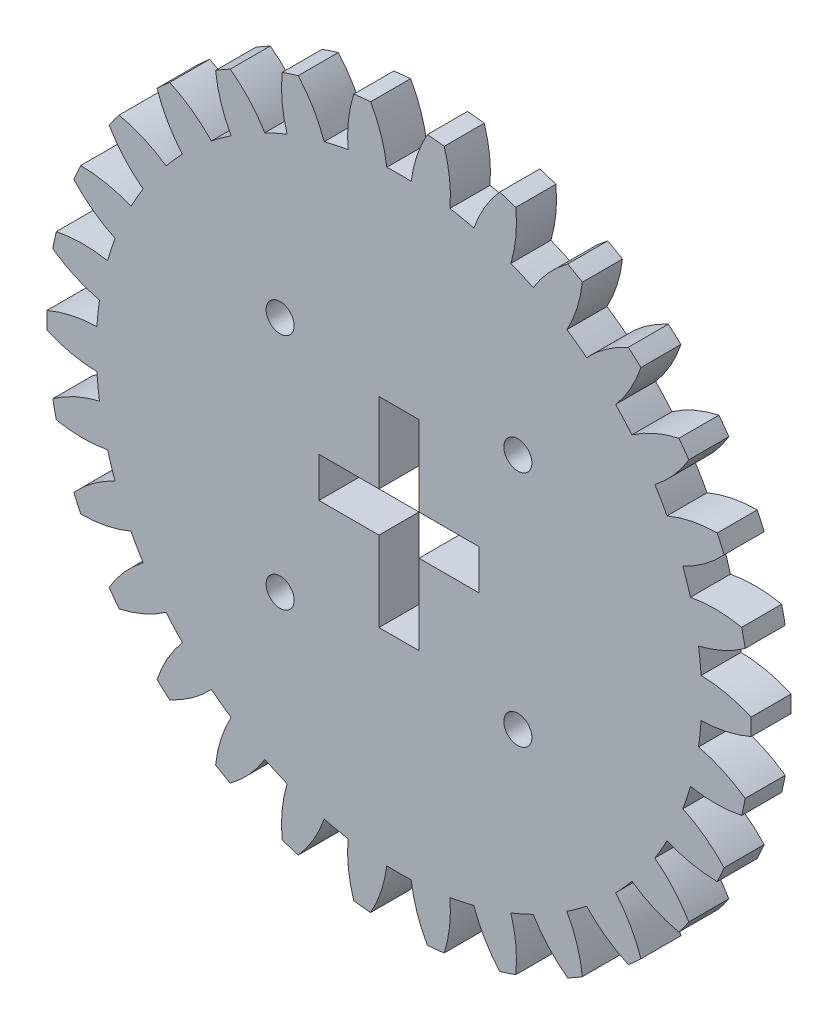
from build123d import *

# Parameters (mm, degrees)
EXTRUDE_1_DEPTH     = 5
SKETCH_2_R          = 1.75
CUT_EXTRUDE_1_DEPTH = 10
CUT_EXTRUDE_2_DEPTH = 10


with BuildPart() as part:
    # 草图1 → 凸台-拉伸1 (new body)
    with BuildSketch(Plane.XY):
        with BuildLine():
            ThreePointArc((-43.98730465, -1.056896208), (-40.927651292, -2.051995365), (-37.733051967, -2.434403732))
            ThreePointArc((-37.733051967, -2.434403732), (-37.604364647, -3.952377989), (-37.414635246, -5.463936465))
            ThreePointArc((-37.414635246, -5.463936465), (-40.459917741, -6.502182838), (-43.245817584, -8.111674394))
            ThreePointArc((-43.245817584, -8.111674394), (-43.038494432, -9.148114396), (-42.806335429, -10.179275375))
            ThreePointArc((-42.806335429, -10.179275375), (-39.606650089, -10.516491524), (-36.402353254, -10.226348803))
            ThreePointArc((-36.402353254, -10.226348803), (-35.960873466, -11.684396083), (-35.461019429, -13.123476419))
            ThreePointArc((-35.461019429, -13.123476419), (-38.223891636, -14.772184451), (-40.614280773, -16.925725901))
            ThreePointArc((-40.614280773, -16.925725901), (-40.196000136, -17.896412295), (-39.754523941, -18.856771362))
            ThreePointArc((-39.754523941, -18.856771362), (-36.554648223, -18.52136654), (-33.480697026, -17.571353361))
            ThreePointArc((-33.480697026, -17.571353361), (-32.745719555, -18.90575), (-31.957586902, -20.20945748))
            ThreePointArc((-31.957586902, -20.20945748), (-34.317298048, -22.396570718), (-36.207705003, -25.000041968))
            ThreePointArc((-36.207705003, -25.000041968), (-35.596747752, -25.862551101), (-34.965248994, -26.710135956))
            ThreePointArc((-34.965248994, -26.710135956), (-31.905032822, -25.716768963), (-29.095773679, -24.14840546))
            ThreePointArc((-29.095773679, -24.14840546), (-28.099420569, -25.300831922), (-27.057454478, -26.412188274))
            ThreePointArc((-27.057454478, -26.412188274), (-28.910873863, -29.042119374), (-30.218678781, -31.981736237))
            ThreePointArc((-30.218678781, -31.981736237), (-29.44174668, -32.698372321), (-28.647824884, -33.396139438))
            ThreePointArc((-28.647824884, -33.396139438), (-25.861014388, -31.788225179), (-23.439225406, -29.670056364))
            ThreePointArc((-23.439225406, -29.670056364), (-22.225042067, -30.590146083), (-20.974781458, -31.4605797))
            ThreePointArc((-20.974781458, -31.4605797), (-22.24090576, -34.418388053), (-22.908951291, -37.565675167))
            ThreePointArc((-22.908951291, -37.565675167), (-22, -38.105117767), (-21.07835336, -38.622571375))
            ThreePointArc((-21.07835336, -38.622571375), (-18.686745531, -36.470383418), (-16.758270509, -33.894983431))
            ThreePointArc((-16.758270509, -33.894983431), (-15.37932258, -34.542524072), (-13.97540984, -35.133992828))
            ThreePointArc((-13.97540984, -35.133992828), (-14.598903352, -38.290408018), (-14.5979927, -41.507813832))
            ThreePointArc((-14.5979927, -41.507813832), (-13.596747752, -41.846486717), (-12.587656648, -42.161011612))
            ThreePointArc((-12.587656648, -42.161011612), (-10.695776226, -39.558610898), (-9.344898775, -36.638537077))
            ThreePointArc((-9.344898775, -36.638537077), (-7.861452897, -36.985228005), (-6.36524575, -37.271881879))
            ThreePointArc((-6.36524575, -37.271881879), (-6.318858814, -40.488953413), (-5.649031779, -43.635861857))
            ThreePointArc((-5.649031779, -43.635861857), (-4.599252384, -43.758963396), (-3.546818938, -43.85681333))
            ThreePointArc((-3.546818938, -43.85681333), (-2.237350175, -40.917937258), (-1.523110123, -37.780810841))
            ThreePointArc((-1.523110123, -37.780810841), (0, -37.8115), (1.523110123, -37.780810841))
            ThreePointArc((1.523110123, -37.780810841), (2.237350175, -40.917937258), (3.546818938, -43.85681333))
            ThreePointArc((3.546818938, -43.85681333), (4.599252384, -43.758963396), (5.649031779, -43.635861857))
            ThreePointArc((5.649031779, -43.635861857), (6.318858814, -40.488953413), (6.36524575, -37.271881879))
            ThreePointArc((6.36524575, -37.271881879), (7.861452897, -36.985228005), (9.344898775, -36.638537077))
            ThreePointArc((9.344898775, -36.638537077), (10.695776226, -39.558610898), (12.587656648, -42.161011612))
            ThreePointArc((12.587656648, -42.161011612), (13.596747752, -41.846486717), (14.5979927, -41.507813832))
            ThreePointArc((14.5979927, -41.507813832), (14.598903352, -38.290408018), (13.97540984, -35.133992828))
            ThreePointArc((13.97540984, -35.133992828), (15.37932258, -34.542524072), (16.758270509, -33.894983431))
            ThreePointArc((16.758270509, -33.894983431), (18.686745531, -36.470383418), (21.07835336, -38.622571375))
            ThreePointArc((21.07835336, -38.622571375), (22, -38.105117767), (22.908951291, -37.565675167))
            ThreePointArc((22.908951291, -37.565675167), (22.24090576, -34.418388053), (20.974781458, -31.4605797))
            ThreePointArc((20.974781458, -31.4605797), (22.225042067, -30.590146083), (23.439225406, -29.670056364))
            ThreePointArc((23.439225406, -29.670056364), (25.861014388, -31.788225179), (28.647824884, -33.396139438))
            ThreePointArc((28.647824884, -33.396139438), (29.44174668, -32.698372321), (30.218678781, -31.981736237))
            ThreePointArc((30.218678781, -31.981736237), (28.910873863, -29.042119374), (27.057454478, -26.412188274))
            ThreePointArc((27.057454478, -26.412188274), (28.099420569, -25.300831922), (29.095773679, -24.14840546))
            ThreePointArc((29.095773679, -24.14840546), (31.905032822, -25.716768963), (34.965248994, -26.710135956))
            ThreePointArc((34.965248994, -26.710135956), (35.596747752, -25.862551101), (36.207705003, -25.000041968))
            ThreePointArc((36.207705003, -25.000041968), (34.317298048, -22.396570718), (31.957586902, -20.20945748))
            ThreePointArc((31.957586902, -20.20945748), (32.745719555, -18.90575), (33.480697026, -17.571353361))
            ThreePointArc((33.480697026, -17.571353361), (36.554648223, -18.52136654), (39.754523941, -18.856771362))
            ThreePointArc((39.754523941, -18.856771362), (40.196000136, -17.896412295), (40.614280773, -16.925725901))
            ThreePointArc((40.614280773, -16.925725901), (38.223891636, -14.772184451), (35.461019429, -13.123476419))
            ThreePointArc((35.461019429, -13.123476419), (35.960873466, -11.684396083), (36.402353254, -10.226348803))
            ThreePointArc((36.402353254, -10.226348803), (39.606650089, -10.516491524), (42.806335429, -10.179275375))
            ThreePointArc((42.806335429, -10.179275375), (43.038494432, -9.148114396), (43.245817584, -8.111674394))
            ThreePointArc((43.245817584, -8.111674394), (40.459917741, -6.502182838), (37.414635246, -5.463936465))
            ThreePointArc((37.414635246, -5.463936465), (37.604364647, -3.952377989), (37.733051967, -2.434403732))
            ThreePointArc((37.733051967, -2.434403732), (40.927651292, -2.051995365), (43.98730465, -1.056896208))
            ThreePointArc((43.98730465, -1.056896208), (44, 0), (43.98730465, 1.056896208))
            ThreePointArc((43.98730465, 1.056896208), (40.927651292, 2.051995365), (37.733051967, 2.434403732))
            ThreePointArc((37.733051967, 2.434403732), (37.604364647, 3.952377989), (37.414635246, 5.463936465))
            ThreePointArc((37.414635246, 5.463936465), (40.459917741, 6.502182838), (43.245817584, 8.111674394))
            ThreePointArc((43.245817584, 8.111674394), (43.038494432, 9.148114396), (42.806335429, 10.179275375))
            ThreePointArc((42.806335429, 10.179275375), (39.606650089, 10.516491524), (36.402353254, 10.226348803))
            ThreePointArc((36.402353254, 10.226348803), (35.960873466, 11.684396083), (35.461019429, 13.123476419))
            ThreePointArc((35.461019429, 13.123476419), (38.223891636, 14.772184451), (40.614280773, 16.925725901))
            ThreePointArc((40.614280773, 16.925725901), (40.196000136, 17.896412295), (39.754523941, 18.856771362))
            ThreePointArc((39.754523941, 18.856771362), (36.554648223, 18.52136654), (33.480697026, 17.571353361))
            ThreePointArc((33.480697026, 17.571353361), (32.745719555, 18.90575), (31.957586902, 20.20945748))
            ThreePointArc((31.957586902, 20.20945748), (34.317298048, 22.396570718), (36.207705003, 25.000041968))
            ThreePointArc((36.207705003, 25.000041968), (35.596747752, 25.862551101), (34.965248994, 26.710135956))
            ThreePointArc((34.965248994, 26.710135956), (31.905032822, 25.716768963), (29.095773679, 24.14840546))
            ThreePointArc((29.095773679, 24.14840546), (28.099420569, 25.300831922), (27.057454478, 26.412188274))
            ThreePointArc((27.057454478, 26.412188274), (28.910873863, 29.042119374), (30.218678781, 31.981736237))
            ThreePointArc((30.218678781, 31.981736237), (29.44174668, 32.698372321), (28.647824884, 33.396139438))
            ThreePointArc((28.647824884, 33.396139438), (25.861014388, 31.788225179), (23.439225406, 29.670056364))
            ThreePointArc((23.439225406, 29.670056364), (22.225042067, 30.590146083), (20.974781458, 31.4605797))
            ThreePointArc((20.974781458, 31.4605797), (22.24090576, 34.418388053), (22.908951291, 37.565675167))
            ThreePointArc((22.908951291, 37.565675167), (22, 38.105117767), (21.07835336, 38.622571375))
            ThreePointArc((21.07835336, 38.622571375), (18.686745531, 36.470383418), (16.758270509, 33.894983431))
            ThreePointArc((16.758270509, 33.894983431), (15.37932258, 34.542524072), (13.97540984, 35.133992828))
            ThreePointArc((13.97540984, 35.133992828), (14.598903352, 38.290408018), (14.5979927, 41.507813832))
            ThreePointArc((14.5979927, 41.507813832), (13.596747752, 41.846486717), (12.587656648, 42.161011612))
            ThreePointArc((12.587656648, 42.161011612), (10.695776226, 39.558610898), (9.344898775, 36.638537077))
            ThreePointArc((9.344898775, 36.638537077), (7.861452897, 36.985228005), (6.36524575, 37.271881879))
            ThreePointArc((6.36524575, 37.271881879), (6.318858814, 40.488953413), (5.649031779, 43.635861857))
            ThreePointArc((5.649031779, 43.635861857), (4.599252384, 43.758963396), (3.546818938, 43.85681333))
            ThreePointArc((3.546818938, 43.85681333), (2.237350175, 40.917937258), (1.523110123, 37.780810841))
            ThreePointArc((1.523110123, 37.780810841), (0, 37.8115), (-1.523110123, 37.780810841))
            ThreePointArc((-1.523110123, 37.780810841), (-2.237350175, 40.917937258), (-3.546818938, 43.85681333))
            ThreePointArc((-3.546818938, 43.85681333), (-4.599252384, 43.758963396), (-5.649031779, 43.635861857))
            ThreePointArc((-5.649031779, 43.635861857), (-6.318858814, 40.488953413), (-6.36524575, 37.271881879))
            ThreePointArc((-6.36524575, 37.271881879), (-7.861452897, 36.985228005), (-9.344898775, 36.638537077))
            ThreePointArc((-9.344898775, 36.638537077), (-10.695776226, 39.558610898), (-12.587656648, 42.161011612))
            ThreePointArc((-12.587656648, 42.161011612), (-13.596747752, 41.846486717), (-14.5979927, 41.507813832))
            ThreePointArc((-14.5979927, 41.507813832), (-14.598903352, 38.290408018), (-13.97540984, 35.133992828))
            ThreePointArc((-13.97540984, 35.133992828), (-15.37932258, 34.542524072), (-16.758270509, 33.894983431))
            ThreePointArc((-16.758270509, 33.894983431), (-18.686745531, 36.470383418), (-21.07835336, 38.622571375))
            ThreePointArc((-21.07835336, 38.622571375), (-22, 38.105117767), (-22.908951291, 37.565675167))
            ThreePointArc((-22.908951291, 37.565675167), (-22.24090576, 34.418388053), (-20.974781458, 31.4605797))
            ThreePointArc((-20.974781458, 31.4605797), (-22.225042067, 30.590146083), (-23.439225406, 29.670056364))
            ThreePointArc((-23.439225406, 29.670056364), (-25.861014388, 31.788225179), (-28.647824884, 33.396139438))
            ThreePointArc((-28.647824884, 33.396139438), (-29.44174668, 32.698372321), (-30.218678781, 31.981736237))
            ThreePointArc((-30.218678781, 31.981736237), (-28.910873863, 29.042119374), (-27.057454478, 26.412188274))
            ThreePointArc((-27.057454478, 26.412188274), (-28.099420569, 25.300831922), (-29.095773679, 24.14840546))
            ThreePointArc((-29.095773679, 24.14840546), (-31.905032822, 25.716768963), (-34.965248994, 26.710135956))
            ThreePointArc((-34.965248994, 26.710135956), (-35.596747752, 25.862551101), (-36.207705003, 25.000041968))
            ThreePointArc((-36.207705003, 25.000041968), (-34.317298048, 22.396570718), (-31.957586902, 20.20945748))
            ThreePointArc((-31.957586902, 20.20945748), (-32.745719555, 18.90575), (-33.480697026, 17.571353361))
            ThreePointArc((-33.480697026, 17.571353361), (-36.554648223, 18.52136654), (-39.754523941, 18.856771362))
            ThreePointArc((-39.754523941, 18.856771362), (-40.196000136, 17.896412295), (-40.614280773, 16.925725901))
            ThreePointArc((-40.614280773, 16.925725901), (-38.223891636, 14.772184451), (-35.461019429, 13.123476419))
            ThreePointArc((-35.461019429, 13.123476419), (-35.960873466, 11.684396083), (-36.402353254, 10.226348803))
            ThreePointArc((-36.402353254, 10.226348803), (-39.606650089, 10.516491524), (-42.806335429, 10.179275375))
            ThreePointArc((-42.806335429, 10.179275375), (-43.038494432, 9.148114396), (-43.245817584, 8.111674394))
            ThreePointArc((-43.245817584, 8.111674394), (-40.459917741, 6.502182838), (-37.414635246, 5.463936465))
            ThreePointArc((-37.414635246, 5.463936465), (-37.604364647, 3.952377989), (-37.733051967, 2.434403732))
            ThreePointArc((-37.733051967, 2.434403732), (-40.927651292, 2.051995365), (-43.98730465, 1.056896208))
            ThreePointArc((-43.98730465, 1.056896208), (-44, 0), (-43.98730465, -1.056896208))
        make_face()
    extrude(amount=EXTRUDE_1_DEPTH)

    # 草图2 → 切除-拉伸1 (cut)
    with BuildSketch(Plane.XY.offset(5)):
        with Locations((14.849242405, 14.849242405)):
            Circle(SKETCH_2_R)
        with Locations((14.849242405, -14.849242405)):
            Circle(SKETCH_2_R)
        with Locations((-14.849242405, -14.849242405)):
            Circle(SKETCH_2_R)
        with Locations((-14.849242405, 14.849242405)):
            Circle(SKETCH_2_R)
    extrude(amount=-CUT_EXTRUDE_1_DEPTH, mode=Mode.SUBTRACT)

    # 草图3 → 切除-拉伸2 (cut)
    with BuildSketch(Plane.XY.offset(5)):
        Polygon((2.5, 2.5), (2.5, 12.5), (-2.5, 12.5), (-2.5, 2.5), (-10, 2.5), (-10, -2.5), (-2.5, -2.5), (-2.5, -12.5), (2.5, -12.5), (2.5, -2.5), (10, -2.5), (10, 2.5), align=None)
    extrude(amount=-CUT_EXTRUDE_2_DEPTH, mode=Mode.SUBTRACT)


solid = part.part
